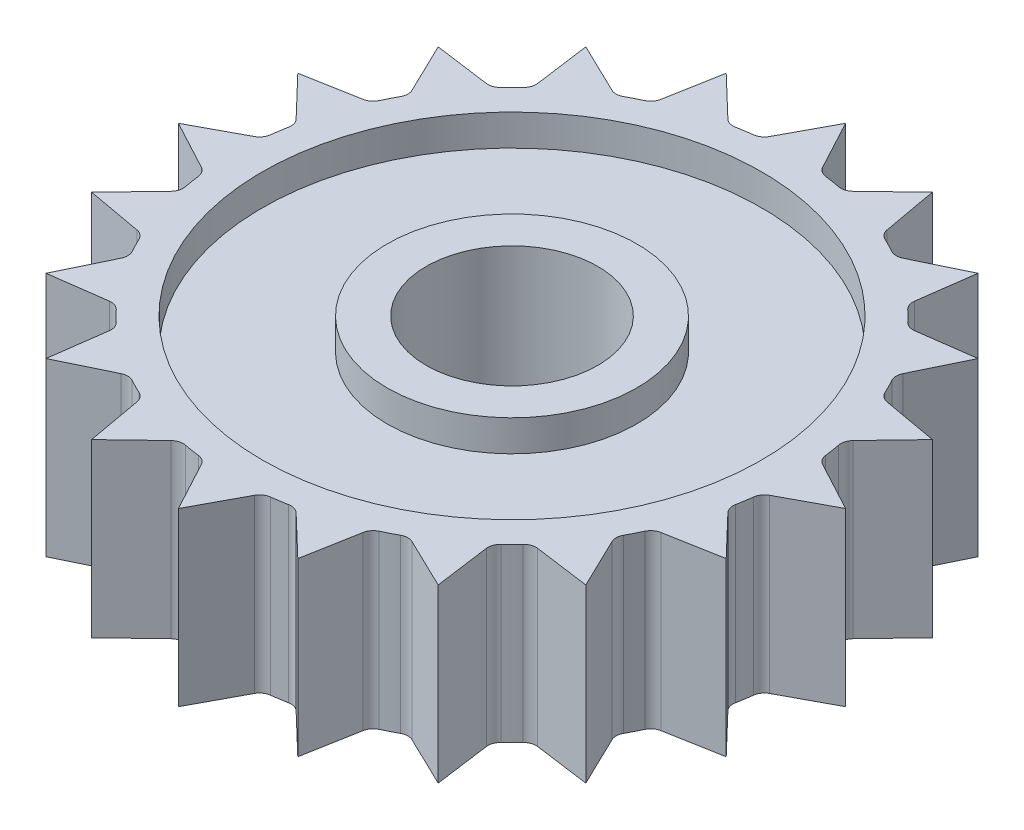
from build123d import *

# Parameters (mm, degrees)
BOSS_EXTRUDE1_DEPTH = 5.5
SKETCH2_R           = 2.75
CUT_EXTRUDE1_DEPTH  = 17.087330419
SKETCH2_3_R         = 8
SKETCH2_3_R_2       = 4
CUT_EXTRUDE2_DEPTH  = 1
CUT_EXTRUDE3_START  = -1
SKETCH3_R           = 8
SKETCH3_R_2         = 4
CUT_EXTRUDE3_DEPTH  = 1


with BuildPart() as part:
    # Sketch1 → Boss-Extrude1 (new body)
    with BuildSketch(Plane(origin=(0, 0, 0), x_dir=(1, 0, 0), z_dir=(0, 1, 0))):
        with BuildLine():
            Line((0, 10.69), (-0.851452759, 9.103207147))
            ThreePointArc((-0.851452759, 9.103207147), (-0.976880558, 8.963010217), (-1.152522076, 8.895650222))
            ThreePointArc((-1.152522076, 8.895650222), (-1.403217151, 8.859564415), (-1.652793464, 8.816415018))
            ThreePointArc((-1.652793464, 8.816415018), (-1.840653858, 8.826201967), (-2.003266017, 8.920777849))
            Line((-2.003266017, 8.920777849), (-3.30339167, 10.166794159))
            Line((-3.30339167, 10.166794159), (-3.622825406, 8.394551104))
            ThreePointArc((-3.622825406, 8.394551104), (-3.698791098, 8.222456579), (-3.845020725, 8.104117202))
            ThreePointArc((-3.845020725, 8.104117202), (-4.072294783, 7.992328522), (-4.296322064, 7.874167684))
            ThreePointArc((-4.296322064, 7.874167684), (-4.478012249, 7.825423572), (-4.661891158, 7.86512066))
            Line((-4.661891158, 7.86512066), (-6.283424347, 8.64839167))
            Line((-6.283424347, 8.64839167), (-6.039570662, 6.864177911))
            ThreePointArc((-6.039570662, 6.864177911), (-6.058638195, 6.677031601), (-6.161141956, 6.519296726))
            ThreePointArc((-6.161141956, 6.519296726), (-6.342747827, 6.342747827), (-6.519296726, 6.161141956))
            ThreePointArc((-6.519296726, 6.161141956), (-6.677031601, 6.058638195), (-6.864177911, 6.039570662))
            Line((-6.864177911, 6.039570662), (-8.64839167, 6.283424347))
            Line((-8.64839167, 6.283424347), (-7.86512066, 4.661891158))
            ThreePointArc((-7.86512066, 4.661891158), (-7.825423572, 4.478012249), (-7.874167684, 4.296322064))
            ThreePointArc((-7.874167684, 4.296322064), (-7.992328522, 4.072294783), (-8.104117202, 3.845020725))
            ThreePointArc((-8.104117202, 3.845020725), (-8.222456579, 3.698791098), (-8.394551104, 3.622825406))
            Line((-8.394551104, 3.622825406), (-10.166794159, 3.30339167))
            Line((-10.166794159, 3.30339167), (-8.920777849, 2.003266017))
            ThreePointArc((-8.920777849, 2.003266017), (-8.826201967, 1.840653858), (-8.816415018, 1.652793464))
            ThreePointArc((-8.816415018, 1.652793464), (-8.859564415, 1.403217151), (-8.895650222, 1.152522076))
            ThreePointArc((-8.895650222, 1.152522076), (-8.963010217, 0.976880558), (-9.103207147, 0.851452759))
            Line((-9.103207147, 0.851452759), (-10.69, 0))
            Line((-10.69, 0), (-9.103207147, -0.851452759))
            ThreePointArc((-9.103207147, -0.851452759), (-8.963010217, -0.976880558), (-8.895650222, -1.152522076))
            ThreePointArc((-8.895650222, -1.152522076), (-8.859564415, -1.403217151), (-8.816415018, -1.652793464))
            ThreePointArc((-8.816415018, -1.652793464), (-8.826201967, -1.840653858), (-8.920777849, -2.003266017))
            Line((-8.920777849, -2.003266017), (-10.166794159, -3.30339167))
            Line((-10.166794159, -3.30339167), (-8.394551104, -3.622825406))
            ThreePointArc((-8.394551104, -3.622825406), (-8.222456579, -3.698791098), (-8.104117202, -3.845020725))
            ThreePointArc((-8.104117202, -3.845020725), (-7.992328522, -4.072294783), (-7.874167684, -4.296322064))
            ThreePointArc((-7.874167684, -4.296322064), (-7.825423572, -4.478012249), (-7.86512066, -4.661891158))
            Line((-7.86512066, -4.661891158), (-8.64839167, -6.283424347))
            Line((-8.64839167, -6.283424347), (-6.864177911, -6.039570662))
            ThreePointArc((-6.864177911, -6.039570662), (-6.677031601, -6.058638195), (-6.519296726, -6.161141956))
            ThreePointArc((-6.519296726, -6.161141956), (-6.342747827, -6.342747827), (-6.161141956, -6.519296726))
            ThreePointArc((-6.161141956, -6.519296726), (-6.058638195, -6.677031601), (-6.039570662, -6.864177911))
            Line((-6.039570662, -6.864177911), (-6.283424347, -8.64839167))
            Line((-6.283424347, -8.64839167), (-4.661891158, -7.86512066))
            ThreePointArc((-4.661891158, -7.86512066), (-4.478012249, -7.825423572), (-4.296322064, -7.874167684))
            ThreePointArc((-4.296322064, -7.874167684), (-4.072294783, -7.992328522), (-3.845020725, -8.104117202))
            ThreePointArc((-3.845020725, -8.104117202), (-3.698791098, -8.222456579), (-3.622825406, -8.394551104))
            Line((-3.622825406, -8.394551104), (-3.30339167, -10.166794159))
            Line((-3.30339167, -10.166794159), (-2.003266017, -8.920777849))
            ThreePointArc((-2.003266017, -8.920777849), (-1.840653858, -8.826201967), (-1.652793464, -8.816415018))
            ThreePointArc((-1.652793464, -8.816415018), (-1.403217151, -8.859564415), (-1.152522076, -8.895650222))
            ThreePointArc((-1.152522076, -8.895650222), (-0.976880558, -8.963010217), (-0.851452759, -9.103207147))
            Line((-0.851452759, -9.103207147), (0, -10.69))
            Line((0, -10.69), (0.851452759, -9.103207147))
            ThreePointArc((0.851452759, -9.103207147), (0.976880558, -8.963010217), (1.152522076, -8.895650222))
            ThreePointArc((1.152522076, -8.895650222), (1.403217151, -8.859564415), (1.652793464, -8.816415018))
            ThreePointArc((1.652793464, -8.816415018), (1.840653858, -8.826201967), (2.003266017, -8.920777849))
            Line((2.003266017, -8.920777849), (3.30339167, -10.166794159))
            Line((3.30339167, -10.166794159), (3.622825406, -8.394551104))
            ThreePointArc((3.622825406, -8.394551104), (3.698791098, -8.222456579), (3.845020725, -8.104117202))
            ThreePointArc((3.845020725, -8.104117202), (4.072294783, -7.992328522), (4.296322064, -7.874167684))
            ThreePointArc((4.296322064, -7.874167684), (4.478012249, -7.825423572), (4.661891158, -7.86512066))
            Line((4.661891158, -7.86512066), (6.283424347, -8.64839167))
            Line((6.283424347, -8.64839167), (6.039570662, -6.864177911))
            ThreePointArc((6.039570662, -6.864177911), (6.058638195, -6.677031601), (6.161141956, -6.519296726))
            ThreePointArc((6.161141956, -6.519296726), (6.342747827, -6.342747827), (6.519296726, -6.161141956))
            ThreePointArc((6.519296726, -6.161141956), (6.677031601, -6.058638195), (6.864177911, -6.039570662))
            Line((6.864177911, -6.039570662), (8.64839167, -6.283424347))
            Line((8.64839167, -6.283424347), (7.86512066, -4.661891158))
            ThreePointArc((7.86512066, -4.661891158), (7.825423572, -4.478012249), (7.874167684, -4.296322064))
            ThreePointArc((7.874167684, -4.296322064), (7.992328522, -4.072294783), (8.104117202, -3.845020725))
            ThreePointArc((8.104117202, -3.845020725), (8.222456579, -3.698791098), (8.394551104, -3.622825406))
            Line((8.394551104, -3.622825406), (10.166794159, -3.30339167))
            Line((10.166794159, -3.30339167), (8.920777849, -2.003266017))
            ThreePointArc((8.920777849, -2.003266017), (8.826201967, -1.840653858), (8.816415018, -1.652793464))
            ThreePointArc((8.816415018, -1.652793464), (8.859564415, -1.403217151), (8.895650222, -1.152522076))
            ThreePointArc((8.895650222, -1.152522076), (8.963010217, -0.976880558), (9.103207147, -0.851452759))
            Line((9.103207147, -0.851452759), (10.69, 0))
            Line((10.69, 0), (9.103207147, 0.851452759))
            ThreePointArc((9.103207147, 0.851452759), (8.963010217, 0.976880558), (8.895650222, 1.152522076))
            ThreePointArc((8.895650222, 1.152522076), (8.859564415, 1.403217151), (8.816415018, 1.652793464))
            ThreePointArc((8.816415018, 1.652793464), (8.826201967, 1.840653858), (8.920777849, 2.003266017))
            Line((8.920777849, 2.003266017), (10.166794159, 3.30339167))
            Line((10.166794159, 3.30339167), (8.394551104, 3.622825406))
            ThreePointArc((8.394551104, 3.622825406), (8.222456579, 3.698791098), (8.104117202, 3.845020725))
            ThreePointArc((8.104117202, 3.845020725), (7.992328522, 4.072294783), (7.874167684, 4.296322064))
            ThreePointArc((7.874167684, 4.296322064), (7.825423572, 4.478012249), (7.86512066, 4.661891158))
            Line((7.86512066, 4.661891158), (8.64839167, 6.283424347))
            Line((8.64839167, 6.283424347), (6.864177911, 6.039570662))
            ThreePointArc((6.864177911, 6.039570662), (6.677031601, 6.058638195), (6.519296726, 6.161141956))
            ThreePointArc((6.519296726, 6.161141956), (6.342747827, 6.342747827), (6.161141956, 6.519296726))
            ThreePointArc((6.161141956, 6.519296726), (6.058638195, 6.677031601), (6.039570662, 6.864177911))
            Line((6.039570662, 6.864177911), (6.283424347, 8.64839167))
            Line((6.283424347, 8.64839167), (4.661891158, 7.86512066))
            ThreePointArc((4.661891158, 7.86512066), (4.478012249, 7.825423572), (4.296322064, 7.874167684))
            ThreePointArc((4.296322064, 7.874167684), (4.072294783, 7.992328522), (3.845020725, 8.104117202))
            ThreePointArc((3.845020725, 8.104117202), (3.698791098, 8.222456579), (3.622825406, 8.394551104))
            Line((3.622825406, 8.394551104), (3.30339167, 10.166794159))
            Line((3.30339167, 10.166794159), (2.003266017, 8.920777849))
            ThreePointArc((2.003266017, 8.920777849), (1.840653858, 8.826201967), (1.652793464, 8.816415018))
            ThreePointArc((1.652793464, 8.816415018), (1.403217151, 8.859564415), (1.152522076, 8.895650222))
            ThreePointArc((1.152522076, 8.895650222), (0.976880558, 8.963010217), (0.851452759, 9.103207147))
            Line((0.851452759, 9.103207147), (0, 10.69))
        make_face()
    extrude(amount=BOSS_EXTRUDE1_DEPTH)

    # Sketch2 → Cut-Extrude1 (cut, through all)
    with BuildSketch(Plane(origin=(0, 5.5, 0), x_dir=(1, 0, 0), z_dir=(0, 1, 0))):
        Circle(SKETCH2_R)
    extrude(amount=-CUT_EXTRUDE1_DEPTH, mode=Mode.SUBTRACT)

    # Sketch2_3 → Cut-Extrude2 (cut)
    with BuildSketch(Plane(origin=(0, 5.5, 0), x_dir=(1, 0, 0), z_dir=(0, 1, 0))):
        Circle(SKETCH2_3_R)
        Circle(SKETCH2_3_R_2, mode=Mode.SUBTRACT)
    extrude(amount=-CUT_EXTRUDE2_DEPTH, mode=Mode.SUBTRACT)

    # Sketch3 → Cut-Extrude3 (cut)
    with BuildSketch(Plane.XZ.offset(CUT_EXTRUDE3_START)):
        Circle(SKETCH3_R)
        Circle(SKETCH3_R_2, mode=Mode.SUBTRACT)
    extrude(amount=CUT_EXTRUDE3_DEPTH, mode=Mode.SUBTRACT)


solid = part.part
